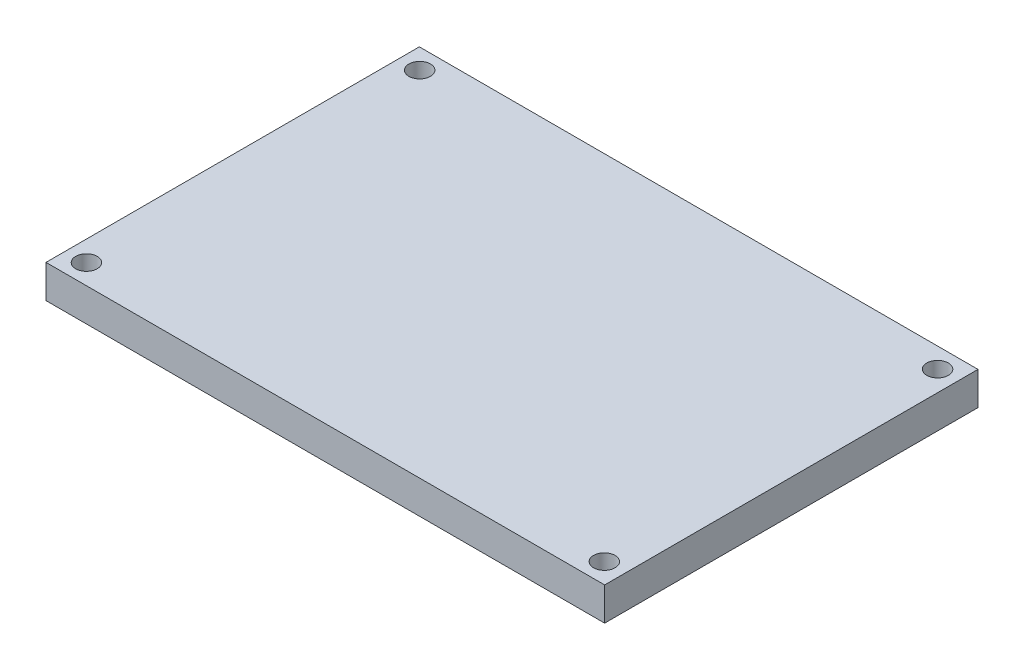
from build123d import *

# Parameters (mm, degrees)
SKETCH1_W           = 84.32
SKETCH1_H           = 56.35
SKETCH1_R           = 1.625
BOSS_EXTRUDE1_DEPTH = 5


with BuildPart() as part:
    # Sketch1 → Boss-Extrude1 (new body)
    with BuildSketch(Plane(origin=(0, 0, 0), x_dir=(1, 0, 0), z_dir=(0, 1, 0))):
        Rectangle(SKETCH1_W, SKETCH1_H)
        with Locations((39.085, 25.15)):
            Circle(SKETCH1_R, mode=Mode.SUBTRACT)
        with Locations((-39.085, 25.15)):
            Circle(SKETCH1_R, mode=Mode.SUBTRACT)
        with Locations((-39.085, -25.15)):
            Circle(SKETCH1_R, mode=Mode.SUBTRACT)
        with Locations((39.085, -25.15)):
            Circle(SKETCH1_R, mode=Mode.SUBTRACT)
    extrude(amount=BOSS_EXTRUDE1_DEPTH)


solid = part.part
